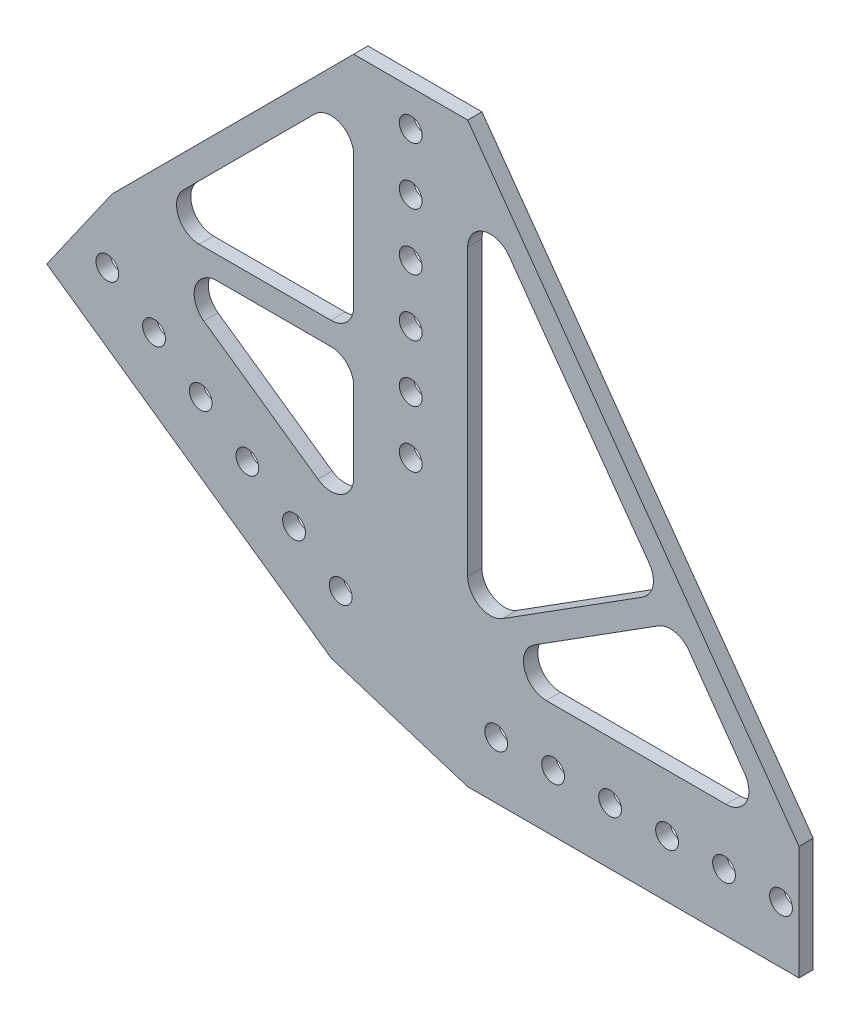
from build123d import *

# Parameters (mm, degrees)
BOSS_EXTRUDE1_DEPTH     = 3.175
SKETCH3_R               = 2.54
CUT_EXTRUDE4_DEPTH      = 4.175
CUT_EXTRUDE4_DEPTH_BACK = 1


with BuildPart() as part:
    # Sketch2 → Boss-Extrude1 (new body)
    with BuildSketch(Plane.XY):
        Polygon((-79.260302653, 74.809862941), (-93.829144137, 54.003401016), (-30.387651704, 9.581189779), (0, 0), (73.861366343, 0), (73.861366343, 25.4), (0, 128.712625375), (-25.4, 128.712625375), align=None)
        with BuildLine():
            Line((-59.82155239, 74.809862941), (-30.48, 74.809862941))
            ThreePointArc((-30.48, 74.809862941), (-26.887897552, 76.297760492), (-25.4, 79.889862941))
            Line((-25.4, 79.889862941), (-25.4, 109.254546205))
            ThreePointArc((-25.4, 109.254546205), (-28.536892808, 113.948237124), (-34.073517496, 112.845233049))
            Line((-34.073517496, 112.845233049), (-63.415069886, 83.480549784))
            ThreePointArc((-63.415069886, 83.480549784), (-64.51447734, 77.944906536), (-59.82155239, 74.809862941))
        make_face(mode=Mode.SUBTRACT)
        with BuildLine():
            Line((-55.893609183, 69.729862941), (-30.48, 69.729862941))
            ThreePointArc((-30.48, 69.729862941), (-26.887897552, 68.241965389), (-25.4, 64.649862941))
            Line((-25.4, 64.649862941), (-25.4, 46.855062218))
            ThreePointArc((-25.4, 46.855062218), (-28.134317045, 42.349047185), (-33.393768297, 42.693769833))
            Line((-33.393768297, 42.693769833), (-58.80737748, 60.488570556))
            ThreePointArc((-58.80737748, 60.488570556), (-60.738491293, 66.177448402), (-55.893609183, 69.729862941))
        make_face(mode=Mode.SUBTRACT)
        with BuildLine():
            Line((7.797059491, 36.347810077), (39.049758479, 56.13093342))
            ThreePointArc((39.049758479, 56.13093342), (41.318484722, 59.449422894), (40.465204003, 63.377705364))
            Line((40.465204003, 63.377705364), (9.212505015, 107.092011536))
            ThreePointArc((9.212505015, 107.092011536), (3.528665973, 108.974887007), (0, 104.137556882))
            Line((0, 104.137556882), (0, 40.640127367))
            ThreePointArc((0, 40.640127367), (2.630128801, 36.189899159), (7.797059491, 36.347810077))
        make_face(mode=Mode.SUBTRACT)
        with BuildLine():
            Line((14.80606505, 34.772317291), (42.476873448, 52.288084993))
            ThreePointArc((42.476873448, 52.288084993), (46.177688514, 52.979604073), (49.338173329, 50.93373836))
            Line((49.338173329, 50.93373836), (61.755602511, 33.417970658))
            ThreePointArc((61.755602511, 33.417970658), (62.124193324, 28.147457497), (57.61136212, 25.4))
            Line((57.61136212, 25.4), (17.52312454, 25.4))
            ThreePointArc((17.52312454, 25.4), (12.644017458, 29.065533994), (14.80606505, 34.772317291))
        make_face(mode=Mode.SUBTRACT)
    extrude(amount=BOSS_EXTRUDE1_DEPTH)

    # Sketch3 → Cut-Extrude4 (cut, two sides)
    with BuildSketch(Plane.XY) as cut_extrude4_sk:
        with Locations((-12.7, 57.15)):
            Circle(SKETCH3_R)
        with Locations((6.35, 12.7)):
            Circle(SKETCH3_R)
        with Locations((-28.304846444, 23.626631112)):
            Circle(SKETCH3_R)
        with Locations((-38.708077406, 30.911051854)):
            Circle(SKETCH3_R)
        with Locations((-49.111308369, 38.195472596)):
            Circle(SKETCH3_R)
        with Locations((-59.514539331, 45.479893337)):
            Circle(SKETCH3_R)
        with Locations((-69.917770294, 52.764314079)):
            Circle(SKETCH3_R)
        with Locations((-80.321001256, 60.048734821)):
            Circle(SKETCH3_R)
        with Locations((-12.7, 69.85)):
            Circle(SKETCH3_R)
        with Locations((-12.7, 82.55)):
            Circle(SKETCH3_R)
        with Locations((-12.7, 95.25)):
            Circle(SKETCH3_R)
        with Locations((-12.7, 107.95)):
            Circle(SKETCH3_R)
        with Locations((-12.7, 120.65)):
            Circle(SKETCH3_R)
        with Locations((19.05, 12.7)):
            Circle(SKETCH3_R)
        with Locations((31.75, 12.7)):
            Circle(SKETCH3_R)
        with Locations((44.45, 12.7)):
            Circle(SKETCH3_R)
        with Locations((57.15, 12.7)):
            Circle(SKETCH3_R)
        with Locations((69.85, 12.7)):
            Circle(SKETCH3_R)
    extrude(amount=CUT_EXTRUDE4_DEPTH, mode=Mode.SUBTRACT)
    extrude(cut_extrude4_sk.sketch, amount=-CUT_EXTRUDE4_DEPTH_BACK, mode=Mode.SUBTRACT)


solid = part.part
